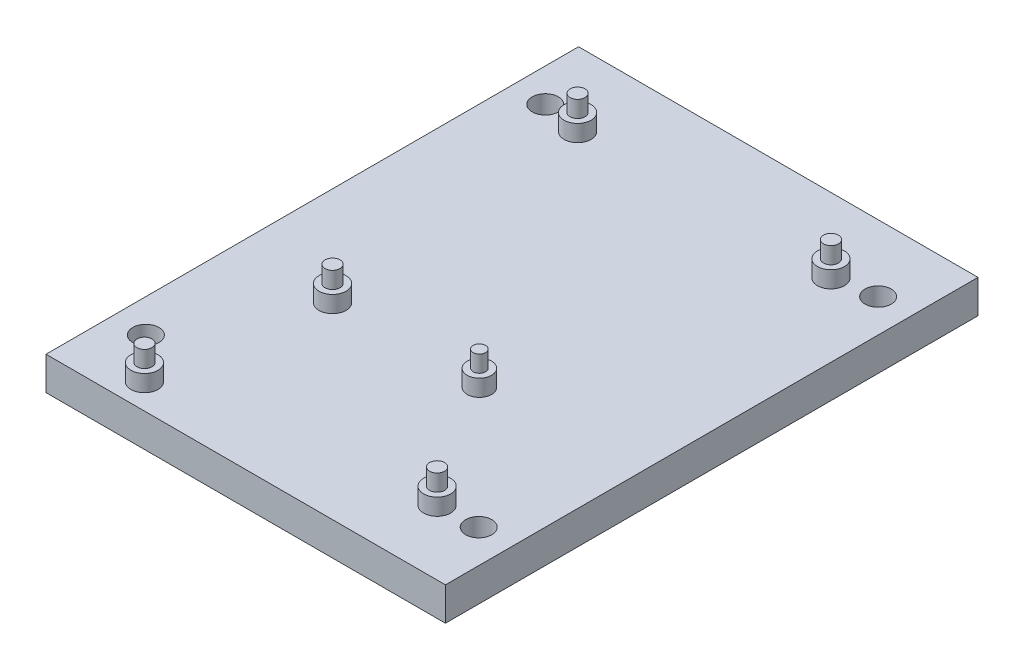
from build123d import *

# Parameters (mm, degrees)
SKETCH1_W           = 76.2
SKETCH1_H           = 101.6
SKETCH1_R           = 2.5
BOSS_EXTRUDE1_DEPTH = 6.35
SKETCH2_R           = 2.5781
SKETCH2_R_2         = 1.4351
SKETCH2_R_3         = 2.331256363
SKETCH2_R_4         = 1.188256363
BOSS_EXTRUDE2_DEPTH = 3.175
BOSS_EXTRUDE3_START = 3.175
SKETCH2_4_R         = 1.4351
SKETCH2_4_R_2       = 1.188256363
BOSS_EXTRUDE3_DEPTH = 3.175


with BuildPart() as part:
    # Sketch1 → Boss-Extrude1 (new body)
    with BuildSketch(Plane(origin=(0, 0, 0), x_dir=(1, 0, 0), z_dir=(0, 1, 0))):
        Rectangle(SKETCH1_W, SKETCH1_H)
        with Locations(Location((-31.75, 38.1, 0), (0, 0, 270))):
            Circle(SKETCH1_R, mode=Mode.SUBTRACT)
        with Locations(Location((-31.75, -38.1, 0), (0, 0, 270))):
            Circle(SKETCH1_R, mode=Mode.SUBTRACT)
        with Locations(Location((31.75, 38.1, 0), (0, 0, 270))):
            Circle(SKETCH1_R, mode=Mode.SUBTRACT)
        with Locations(Location((31.75, -38.1, 0), (0, 0, 270))):
            Circle(SKETCH1_R, mode=Mode.SUBTRACT)
    extrude(amount=BOSS_EXTRUDE1_DEPTH)

    # Sketch2 → Boss-Extrude2 (add)
    with BuildSketch(Plane(origin=(0, 6.35, 0), x_dir=(1, 0, 0), z_dir=(0, 1, 0))):
        with Locations(Location((-24.1681, 36.6776, 0), (0, 0, 90))):
            Circle(SKETCH2_R)
        with Locations((-24.1681, 36.6776)):
            Circle(SKETCH2_R_2, mode=Mode.SUBTRACT)
        with Locations((-24.1681, 36.6776)):
            Circle(SKETCH2_R_2)
        with Locations(Location((24.1681, 36.6776, 0), (0, 0, 90))):
            Circle(SKETCH2_R)
        with Locations((24.1681, 36.6776)):
            Circle(SKETCH2_R_2, mode=Mode.SUBTRACT)
        with Locations((24.1681, 36.6776)):
            Circle(SKETCH2_R_2)
        with Locations(Location((-19.289607234, -14.9479, 0), (0, 0, 90))):
            Circle(SKETCH2_R)
        with Locations((-19.289607234, -14.9479)):
            Circle(SKETCH2_R_2, mode=Mode.SUBTRACT)
        with Locations((-19.289607234, -14.9479)):
            Circle(SKETCH2_R_2)
        with Locations(Location((8.726592766, -14.9479, 0), (0, 0, 90))):
            Circle(SKETCH2_R_3)
        with Locations((8.726592766, -14.9479)):
            Circle(SKETCH2_R_4, mode=Mode.SUBTRACT)
        with Locations((8.726592766, -14.9479)):
            Circle(SKETCH2_R_4)
        with Locations(Location((-24.1681, -45.9486, 0), (0, 0, 90))):
            Circle(SKETCH2_R)
        with Locations((-24.1681, -45.9486)):
            Circle(SKETCH2_R_2, mode=Mode.SUBTRACT)
        with Locations((-24.1681, -45.9486)):
            Circle(SKETCH2_R_2)
        with Locations(Location((24.1681, -38.4556, 0), (0, 0, 90))):
            Circle(SKETCH2_R)
        with Locations((24.1681, -38.4556)):
            Circle(SKETCH2_R_2, mode=Mode.SUBTRACT)
        with Locations((24.1681, -38.4556)):
            Circle(SKETCH2_R_2)
    extrude(amount=BOSS_EXTRUDE2_DEPTH)

    # Sketch2_4 → Boss-Extrude3 (add)
    with BuildSketch(Plane(origin=(0, 6.35, 0), x_dir=(1, 0, 0), z_dir=(0, 1, 0)).offset(BOSS_EXTRUDE3_START)):
        with Locations(Location((-24.1681, 36.6776, 0), (0, 0, 270))):
            Circle(SKETCH2_4_R)
        with Locations(Location((24.1681, 36.6776, 0), (0, 0, 270))):
            Circle(SKETCH2_4_R)
        with Locations(Location((-19.289607234, -14.9479, 0), (0, 0, 270))):
            Circle(SKETCH2_4_R)
        with Locations(Location((8.726592766, -14.9479, 0), (0, 0, 270))):
            Circle(SKETCH2_4_R_2)
        with Locations(Location((24.1681, -38.4556, 0), (0, 0, 270))):
            Circle(SKETCH2_4_R)
        with Locations(Location((-24.1681, -45.9486, 0), (0, 0, 270))):
            Circle(SKETCH2_4_R)
    extrude(amount=BOSS_EXTRUDE3_DEPTH)


solid = part.part
